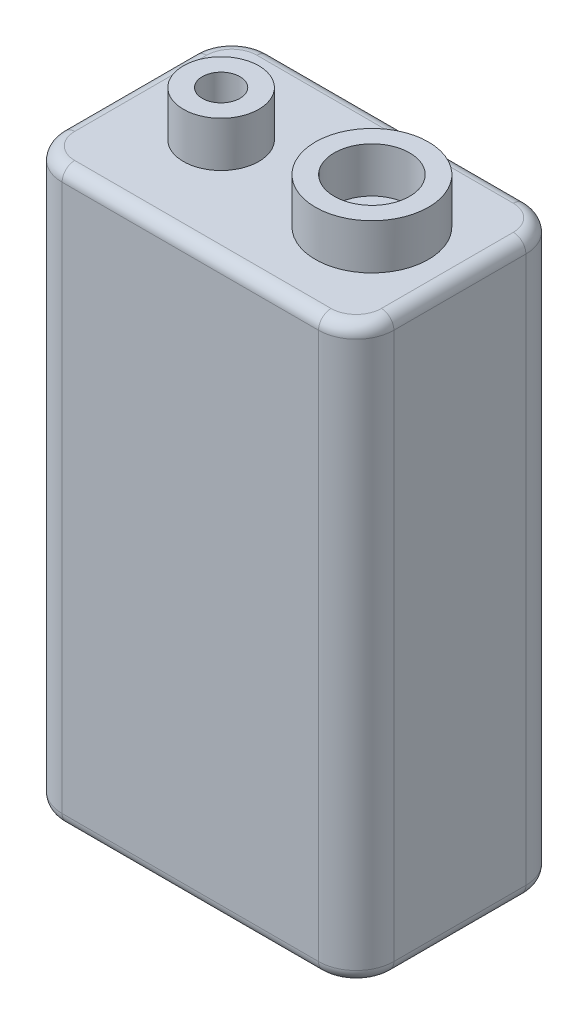
from build123d import *

# Parameters (mm, degrees)
SKETCH_1_W      = 26.4
SKETCH_1_H      = 45.5
EXTRUDE_1_DEPTH = 16.5
FILLET_1_R      = 3
SKETCH_2_R      = 3
SKETCH_2_R_2    = 1.5
SKETCH_2_R_3    = 4.5
EXTRUDE_2_DEPTH = 3.6
FILLET_2_R      = 1


with BuildPart() as part:
    # 草圖1 → 填料-伸長1 (new body)
    with BuildSketch(Plane.XY):
        with Locations((13.2, 22.75)):
            Rectangle(SKETCH_1_W, SKETCH_1_H)
    extrude(amount=EXTRUDE_1_DEPTH)

    # 圓角1
    fillet_1_edges = [part.edges().sort_by_distance(p)[0] for p in [
        (26.4, 22.75, 16.5),
        (0, 22.75, 16.5),
        (26.4, 22.75, 0),
        (0, 22.75, 0),
    ]]
    fillet(fillet_1_edges, radius=FILLET_1_R)

    # 草圖2 → 填料-伸長2 (add)
    with BuildSketch(Plane(origin=(0, 45.5, 0), x_dir=(1, 0, 0), z_dir=(0, 1, 0))):
        with Locations((7.4, -8.25)):
            Circle(SKETCH_2_R)
        with Locations((7.4, -8.25)):
            Circle(SKETCH_2_R_2, mode=Mode.SUBTRACT)
        with Locations((19.4, -8.25)):
            Circle(SKETCH_2_R_3)
        with Locations((19.4, -8.25)):
            Circle(SKETCH_2_R, mode=Mode.SUBTRACT)
    extrude(amount=EXTRUDE_2_DEPTH)

    # 圓角2
    fillet_2_edges = [part.edges().sort_by_distance(p)[0] for p in [
        (0, 0, 8.25),
        (0, 45.5, 8.25),
        (13.2, 0, 0),
        (26.4, 0, 8.25),
        (13.2, 0, 16.5),
        (25.521320344, 0, 15.621320344),
        (25.521320344, 0, 0.878679656),
        (0.878679656, 0, 15.621320344),
        (0.878679656, 0, 0.878679656),
        (13.2, 45.5, 0),
        (13.2, 45.5, 16.5),
        (26.4, 45.5, 8.25),
        (25.521320344, 45.5, 15.621320344),
        (25.521320344, 45.5, 0.878679656),
        (0.878679656, 45.5, 15.621320344),
        (0.878679656, 45.5, 0.878679656),
    ]]
    fillet(fillet_2_edges, radius=FILLET_2_R)


solid = part.part
